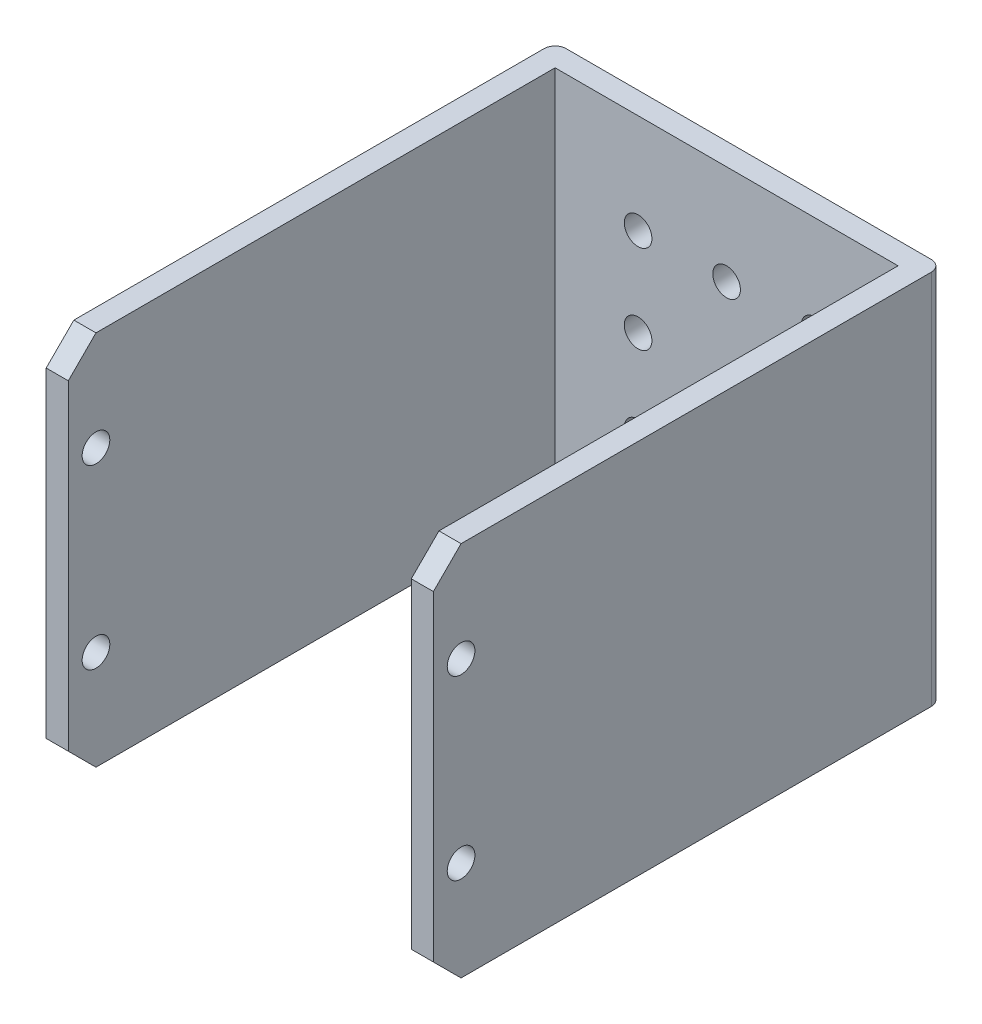
from build123d import *

# Parameters (mm, degrees)
SKETCH1_W           = 35
SKETCH1_H           = 34
BOSS_EXTRUDE1_DEPTH = 46
SKETCH3_W           = 31
SKETCH3_H           = 34
CUT_EXTRUDE1_DEPTH  = 44
FILLET1_R           = 1
CHAMFER1_SIZE       = 2.5
SKETCH4_R           = 1.25
CUT_EXTRUDE2_DEPTH  = 40.5
SKETCH7_R           = 1.25
CUT_EXTRUDE3_DEPTH  = 5


with BuildPart() as part:
    # Sketch1 → Boss-Extrude1 (new body)
    with BuildSketch(Plane.XY):
        with Locations((17.5, 17)):
            Rectangle(SKETCH1_W, SKETCH1_H)
    extrude(amount=BOSS_EXTRUDE1_DEPTH)

    # Sketch3 → Cut-Extrude1 (cut)
    with BuildSketch(Plane.XY.offset(46)):
        with Locations((17.5, 17)):
            Rectangle(SKETCH3_W, SKETCH3_H)
    extrude(amount=-CUT_EXTRUDE1_DEPTH, mode=Mode.SUBTRACT)

    # Fillet1
    fillet1_edges = [part.edges().sort_by_distance(p)[0] for p in [
        (0, 17, 0),
        (35, 17, 0),
    ]]
    fillet(fillet1_edges, radius=FILLET1_R)

    # Chamfer1
    chamfer1_edges = [part.edges().sort_by_distance(p)[0] for p in [
        (1, 0, 46),
        (1, 34, 46),
        (34, 0, 46),
        (34, 34, 46),
    ]]
    chamfer(chamfer1_edges, length=CHAMFER1_SIZE)

    # Sketch4 → Cut-Extrude2 (cut)
    with BuildSketch(Plane.ZY):
        with Locations((43.5, 25)):
            Circle(SKETCH4_R)
        with Locations((43.5, 9)):
            Circle(SKETCH4_R)
    extrude(amount=-CUT_EXTRUDE2_DEPTH, mode=Mode.SUBTRACT)

    # Sketch7 → Cut-Extrude3 (cut)
    with BuildSketch(Plane.XY.offset(2)):
        with Locations((9.5, 9)):
            Circle(SKETCH7_R)
        with Locations((17.5, 9)):
            Circle(SKETCH7_R)
        with Locations((25.5, 9)):
            Circle(SKETCH7_R)
        with Locations((25.5, 17)):
            Circle(SKETCH7_R)
        with Locations((17.5, 25)):
            Circle(SKETCH7_R)
        with Locations((25.5, 25)):
            Circle(SKETCH7_R)
        with Locations((9.5, 17)):
            Circle(SKETCH7_R)
        with Locations((9.5, 25)):
            Circle(SKETCH7_R)
    extrude(amount=-CUT_EXTRUDE3_DEPTH, mode=Mode.SUBTRACT)


solid = part.part
